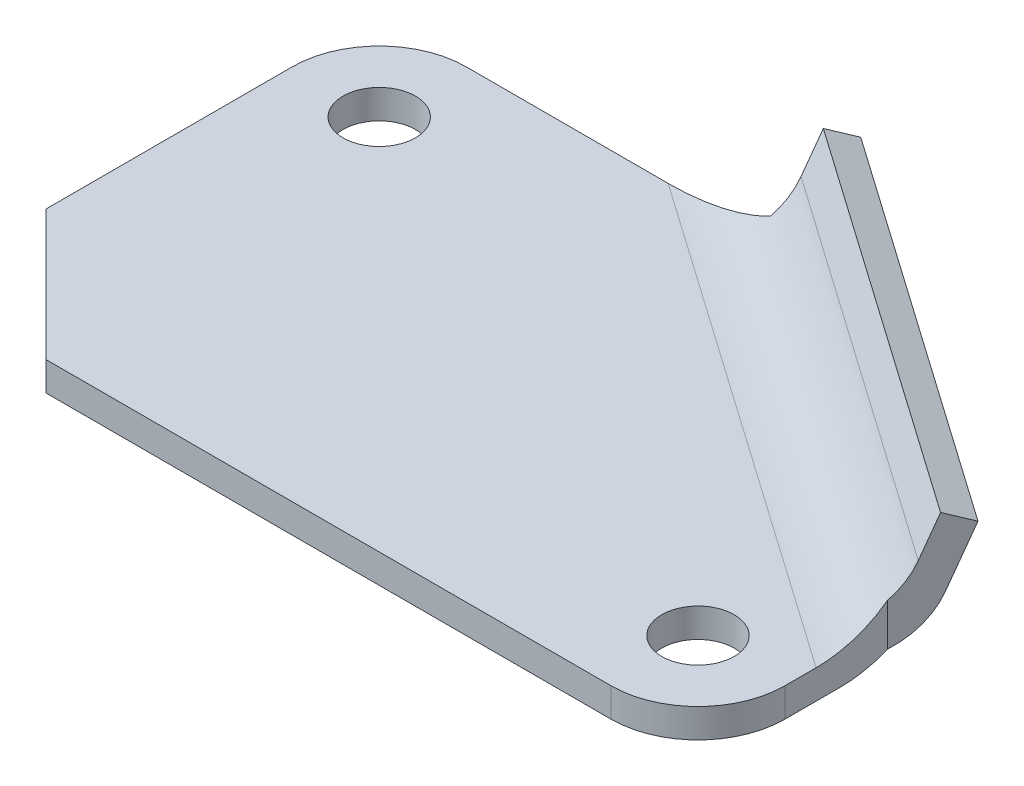
from build123d import *

# Parameters (mm, degrees)
SKETCH1_R           = 5
BOSS_EXTRUDE1_DEPTH = 2
BOSS_EXTRUDE2_DEPTH = 65.921828
FILLET1_R           = 12
FILLET2_R           = 12


with BuildPart() as part:
    # Sketch1 → Boss-Extrude1 (new body, symmetric)
    with BuildSketch(Plane(origin=(0, 0, 0), x_dir=(1, 0, 0), z_dir=(0, 1, 0))):
        with BuildLine():
            Line((0, 18), (18, 0))
            Line((18, 0), (96, 0))
            ThreePointArc((96, 0), (104.485281374, 3.514718626), (108, 12))
            Line((108, 12), (108, 26.188792937))
            Line((108, 26.188792937), (54, 64))
            Line((54, 64), (12, 64))
            ThreePointArc((12, 64), (3.514718626, 60.485281374), (0, 52))
            Line((0, 52), (0, 18))
        make_face()
        with Locations((12, 52)):
            Circle(SKETCH1_R, mode=Mode.SUBTRACT)
        with Locations((96, 12)):
            Circle(SKETCH1_R, mode=Mode.SUBTRACT)
    extrude(amount=BOSS_EXTRUDE1_DEPTH, both=True)

    # Sketch4 → Boss-Extrude2 (add)
    with BuildSketch(Plane(origin=(60.164380005, 0, 42.127552411), x_dir=(0.573576436, 0, -0.819152044), z_dir=(0.819152044, 0, 0.573576436))):
        Polygon((83.398858397, 2), (88.643350705, 14.980573964), (92.352086124, 13.48214759), (86.096892465, -2), (83.398858397, -2), align=None)
    extrude(amount=-BOSS_EXTRUDE2_DEPTH)

    # Fillet1
    fillet1_edges = [part.edges().sort_by_distance(p)[0] for p in [
        (82.547528681, -2, -47.30449665),
    ]]
    fillet(fillet1_edges, radius=FILLET1_R)

    # Fillet2
    fillet2_edges = [part.edges().sort_by_distance(p)[0] for p in [
        (81, 2, -45.094396468),
    ]]
    fillet(fillet2_edges, radius=FILLET2_R)


solid = part.part
